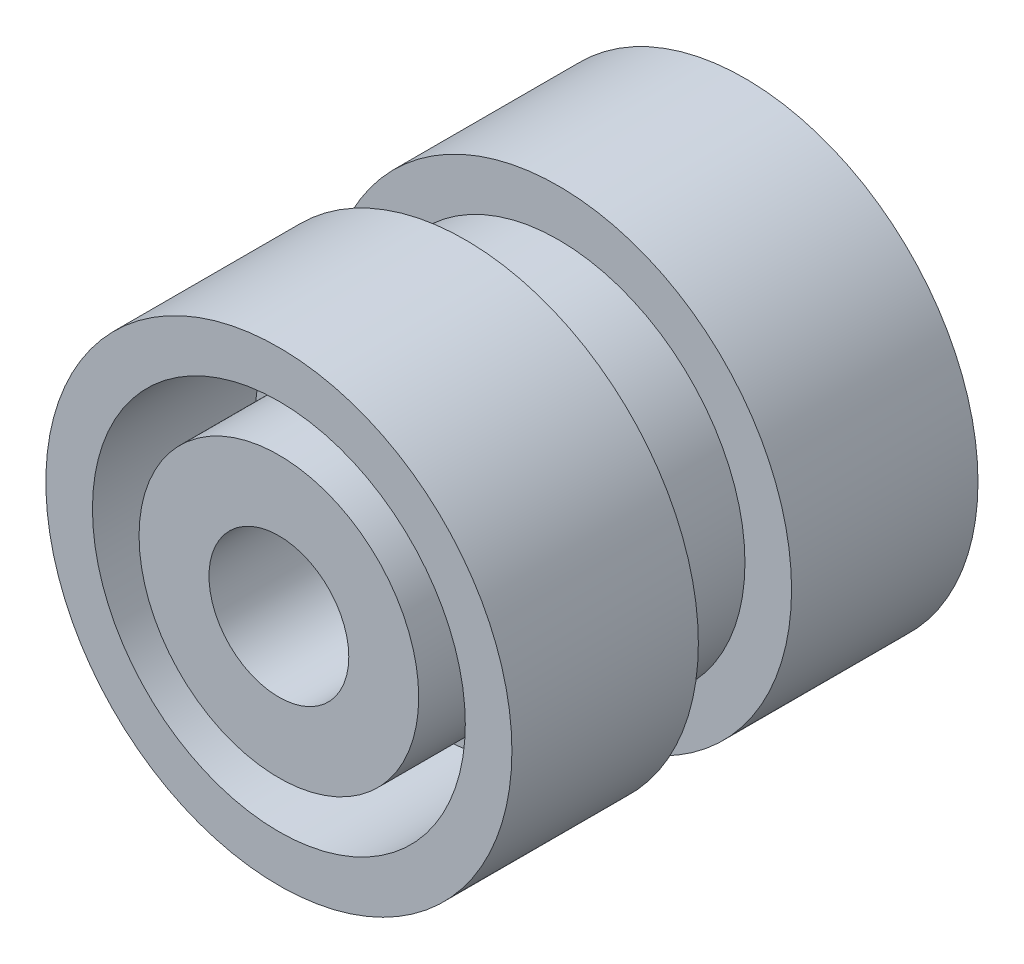
from build123d import *

# Parameters (mm, degrees)
BOSS_EXTRUDE1_DEPTH = 2
SKETCH9_R           = 1.5
CUT_EXTRUDE2_DEPTH  = 8


with BuildPart() as part:
    # Sketch1 → Revolve1 (revolve)
    with BuildSketch(Plane(origin=(0, 0, 0), x_dir=(0, 0, -1), z_dir=(1, 0, 0))):
        Polygon((0, 0), (1.5, 0), (1.5, 4), (5, 4), (5, 5), (1, 5), (1, 4), (-1, 4), (-1, 5), (-5, 5), (-5, 4), (-1.5, 4), (-1.5, 3), (-5, 3), (-5, 0), align=None)
    revolve(axis=Axis((0, 0, 8.435401075), (0, 0, -1)))

    # Sketch8 → Boss-Extrude1 (add)
    with BuildSketch(Plane(origin=(0, 0, -1.5), x_dir=(-1, 0, 0), z_dir=(0, 0, -1))):
        with BuildLine():
            Line((-0.5, 3.968626967), (-0.5, 1.936491673))
            ThreePointArc((-0.5, 1.936491673), (-1.414213562, 1.414213562), (-1.936491673, 0.5))
            Line((-1.936491673, 0.5), (-3.968626967, 0.5))
            ThreePointArc((-3.968626967, 0.5), (-4, 0), (-3.968626967, -0.5))
            Line((-3.968626967, -0.5), (-1.936491673, -0.5))
            ThreePointArc((-1.936491673, -0.5), (-1.414213562, -1.414213562), (-0.5, -1.936491673))
            Line((-0.5, -1.936491673), (-0.5, -3.968626967))
            ThreePointArc((-0.5, -3.968626967), (0, -4), (0.5, -3.968626967))
            Line((0.5, -3.968626967), (0.5, -1.936491673))
            ThreePointArc((0.5, -1.936491673), (1.414213562, -1.414213562), (1.936491673, -0.5))
            Line((1.936491673, -0.5), (3.968626967, -0.5))
            ThreePointArc((3.968626967, -0.5), (4, 0), (3.968626967, 0.5))
            Line((3.968626967, 0.5), (1.936491673, 0.5))
            ThreePointArc((1.936491673, 0.5), (1.414213562, 1.414213562), (0.5, 1.936491673))
            Line((0.5, 1.936491673), (0.5, 3.968626967))
            ThreePointArc((0.5, 3.968626967), (0, 4), (-0.5, 3.968626967))
        make_face()
    extrude(amount=BOSS_EXTRUDE1_DEPTH)

    # Sketch9 → Cut-Extrude2 (cut)
    with BuildSketch(Plane.XY.offset(5)):
        Circle(SKETCH9_R)
    extrude(amount=-CUT_EXTRUDE2_DEPTH, mode=Mode.SUBTRACT)


solid = part.part
